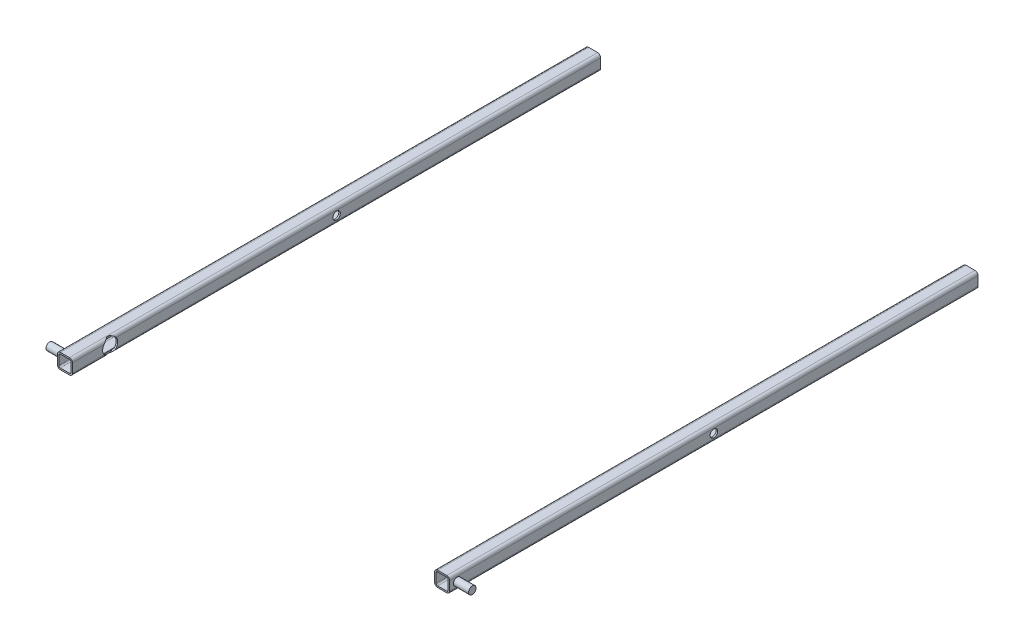
from build123d import *

# Parameters (mm, degrees)
SQUARE_TUBE_CONFIGURED_20_X_20_X_2_1_DEPTH   = 700
SQUARE_TUBE_CONFIGURED_20_X_20_X_2_1_2_DEPTH = 700
SKETCH15_R                                   = 5
CUT_EXTRUDE1_DEPTH                           = 520.807656735
CUT_EXTRUDE1_DEPTH_BACK                      = 520.807656735
SKETCH16_R                                   = 5
BOSS_EXTRUDE2_DEPTH                          = 20
SKETCH13_R                                   = 10
CUT_EXTRUDE3_DEPTH                           = 483
CUT_EXTRUDE3_DEPTH_BACK                      = 2


with BuildPart() as part:
    # Sketch111 → Square tube - configured 20 X 20 X 2(1) (new body)
    with BuildSketch(Plane(origin=(-250, 0, -450), x_dir=(1, 0, 0), z_dir=(0, 0, 1))):
        with BuildLine():
            Line((-6, -10), (6, -10))
            ThreePointArc((6, -10), (8.828427125, -8.828427125), (10, -6))
            Line((10, -6), (10, 6))
            ThreePointArc((10, 6), (8.828427125, 8.828427125), (6, 10))
            Line((6, 10), (-6, 10))
            ThreePointArc((-6, 10), (-8.828427125, 8.828427125), (-10, 6))
            Line((-10, 6), (-10, -6))
            ThreePointArc((-10, -6), (-8.828427125, -8.828427125), (-6, -10))
        make_face()
        with BuildLine():
            Line((-6, -8), (6, -8))
            ThreePointArc((6, -8), (7.414213562, -7.414213562), (8, -6))
            Line((8, -6), (8, 6))
            ThreePointArc((8, 6), (7.414213562, 7.414213562), (6, 8))
            Line((6, 8), (-6, 8))
            ThreePointArc((-6, 8), (-7.414213562, 7.414213562), (-8, 6))
            Line((-8, 6), (-8, -6))
            ThreePointArc((-8, -6), (-7.414213562, -7.414213562), (-6, -8))
        make_face(mode=Mode.SUBTRACT)
    extrude(amount=SQUARE_TUBE_CONFIGURED_20_X_20_X_2_1_DEPTH)


with BuildPart() as body_2:
    # Sketch111 on segment 2 (carried to segment 2) → Square tube - configured 20 X 20 X 2_1 2 (new body)
    with BuildSketch(Plane(origin=(250, 0, -450), x_dir=(1, 0, 0), z_dir=(0, 0, 1))):
        with BuildLine():
            Line((-6, -10), (6, -10))
            ThreePointArc((6, -10), (8.828427125, -8.828427125), (10, -6))
            Line((10, -6), (10, 6))
            ThreePointArc((10, 6), (8.828427125, 8.828427125), (6, 10))
            Line((6, 10), (-6, 10))
            ThreePointArc((-6, 10), (-8.828427125, 8.828427125), (-10, 6))
            Line((-10, 6), (-10, -6))
            ThreePointArc((-10, -6), (-8.828427125, -8.828427125), (-6, -10))
        make_face()
        with BuildLine():
            Line((-6, -8), (6, -8))
            ThreePointArc((6, -8), (7.414213562, -7.414213562), (8, -6))
            Line((8, -6), (8, 6))
            ThreePointArc((8, 6), (7.414213562, 7.414213562), (6, 8))
            Line((6, 8), (-6, 8))
            ThreePointArc((-6, 8), (-7.414213562, 7.414213562), (-8, 6))
            Line((-8, 6), (-8, -6))
            ThreePointArc((-8, -6), (-7.414213562, -7.414213562), (-6, -8))
        make_face(mode=Mode.SUBTRACT)
    extrude(amount=SQUARE_TUBE_CONFIGURED_20_X_20_X_2_1_2_DEPTH)


with BuildPart() as cut_extrude1_tool:
    # Sketch15 → Cut-Extrude1 (new, two sides)
    with BuildSketch(Plane(origin=(0, 0, 0), x_dir=(0, 0, -1), z_dir=(1, 0, 0))) as cut_extrude1_sk:
        with Locations((100, 0)):
            Circle(SKETCH15_R)
    extrude(amount=CUT_EXTRUDE1_DEPTH)
    extrude(cut_extrude1_sk.sketch, amount=-CUT_EXTRUDE1_DEPTH_BACK)


with BuildPart() as part_1:
    add(part.part)

    # Cut-Extrude1: cut by cut_extrude1_tool
    add(cut_extrude1_tool.part, mode=Mode.SUBTRACT)


with BuildPart() as body_2_1:
    add(body_2.part)

    # Cut-Extrude1: cut by cut_extrude1_tool
    add(cut_extrude1_tool.part, mode=Mode.SUBTRACT)


with BuildPart() as body_3:
    # Sketch16 → Boss-Extrude2 (new body)
    with BuildSketch(Plane.ZY.offset(260)):
        with Locations((240, 0)):
            Circle(SKETCH16_R)
    boss_extrude2 = extrude(amount=BOSS_EXTRUDE2_DEPTH)


with BuildPart() as body_2_2:
    add(body_2_1.part)

    # Mirror2: Boss-Extrude2 across plane
    add(boss_extrude2.mirror(Plane(origin=(0, 0, 0), x_dir=(0, 0, 1), z_dir=(1, 0, 0))))


with BuildPart() as cut_extrude3_tool:
    # Sketch13 → Cut-Extrude3 (new, two sides)
    with BuildSketch(Plane.ZY.offset(-240)) as cut_extrude3_sk:
        with Locations((200, 0)):
            Circle(SKETCH13_R)
    extrude(amount=CUT_EXTRUDE3_DEPTH)
    extrude(cut_extrude3_sk.sketch, amount=-CUT_EXTRUDE3_DEPTH_BACK)


with BuildPart() as part_2:
    add(part_1.part)

    # Cut-Extrude3: cut by cut_extrude3_tool
    add(cut_extrude3_tool.part, mode=Mode.SUBTRACT)


with BuildPart() as body_2_3:
    add(body_2_2.part)

    # Cut-Extrude3: cut by cut_extrude3_tool
    add(cut_extrude3_tool.part, mode=Mode.SUBTRACT)


solid = Compound([body_3.part, part_2.part, body_2_3.part])
